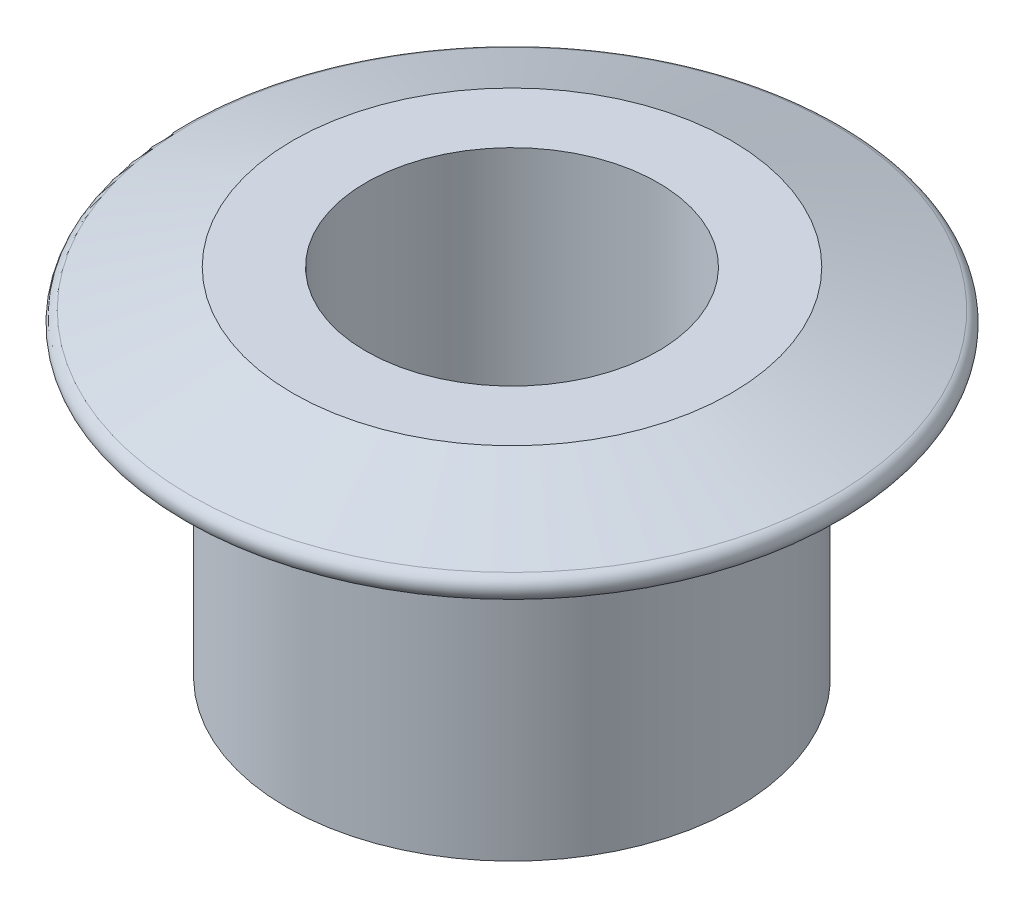
from build123d import *

# Parameters (mm, degrees)
CUT_EXTRUDE1_REACH = 31.21
SKETCH2_R          = 12
FILLET1_R          = 1


with BuildPart() as part:
    # Sketch1 → Revolve1 (revolve)
    with BuildSketch(Plane.XY):
        Polygon((0, 5), (18, 5), (31.76, 0), (18.5, 0), (18.5, -24.21), (0, -24.21), align=None)
    revolve(axis=Axis((0, 25.060687023, 0), (0, -1, 0)))

    # Sketch2 → Cut-Extrude1 (cut, up to next)
    with BuildSketch(Plane(origin=(0, 5, 0), x_dir=(1, 0, 0), z_dir=(0, 1, 0)), mode=Mode.PRIVATE) as cut_extrude1_sk1:
        Circle(SKETCH2_R)
    cut_extrude1_tool1 = extrude(cut_extrude1_sk1.sketch, amount=-CUT_EXTRUDE1_REACH, mode=Mode.PRIVATE) & part.part
    add(cut_extrude1_tool1.solids().sort_by_distance((0, 5, 0))[0], mode=Mode.SUBTRACT)

    # Fillet1
    fillet1_edges = [part.edges().sort_by_distance(p)[0] for p in [
        (-31.76, 0, 0),
    ]]
    fillet(fillet1_edges, radius=FILLET1_R)


solid = part.part
